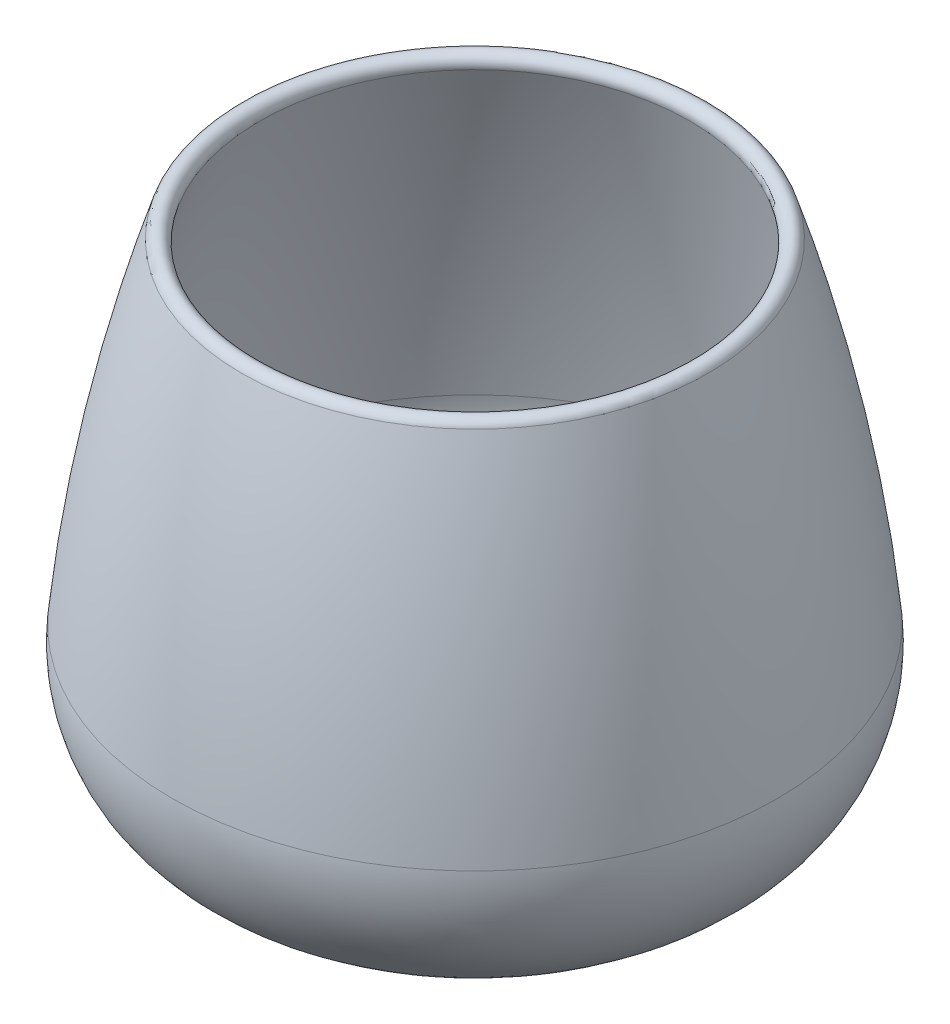
from build123d import *


with BuildPart() as part:
    # Sketch1 → Revolve1 (revolve)
    with BuildSketch(Plane.XY):
        with BuildLine():
            Line((0, 0), (12.7, 0))
            ThreePointArc((12.7, 0), (18.686592918, 0.271905112), (24.623888889, 1.085381429))
            ThreePointArc((24.623888889, 1.085381429), (37.202366298, 8.867914793), (41.171799597, 23.11675751))
            ThreePointArc((41.171799597, 23.11675751), (37.638540624, 46.092432968), (31.75, 68.58))
            ThreePointArc((31.75, 68.58), (30.154868715, 69.405443023), (29.329425692, 67.810311739))
            ThreePointArc((29.329425692, 67.810311739), (35.151388742, 45.576995764), (38.644699647, 22.861090061))
            ThreePointArc((38.644699647, 22.861090061), (35.171445511, 10.393352683), (24.165277778, 3.583635989))
            ThreePointArc((24.165277778, 3.583635989), (18.456339345, 2.801447223), (12.7, 2.54))
            Line((12.7, 2.54), (0, 2.54))
            Line((0, 2.54), (0, 0))
        make_face()
    revolve(axis=Axis((0, 0, 0), (0, 1, 0)))


solid = part.part
